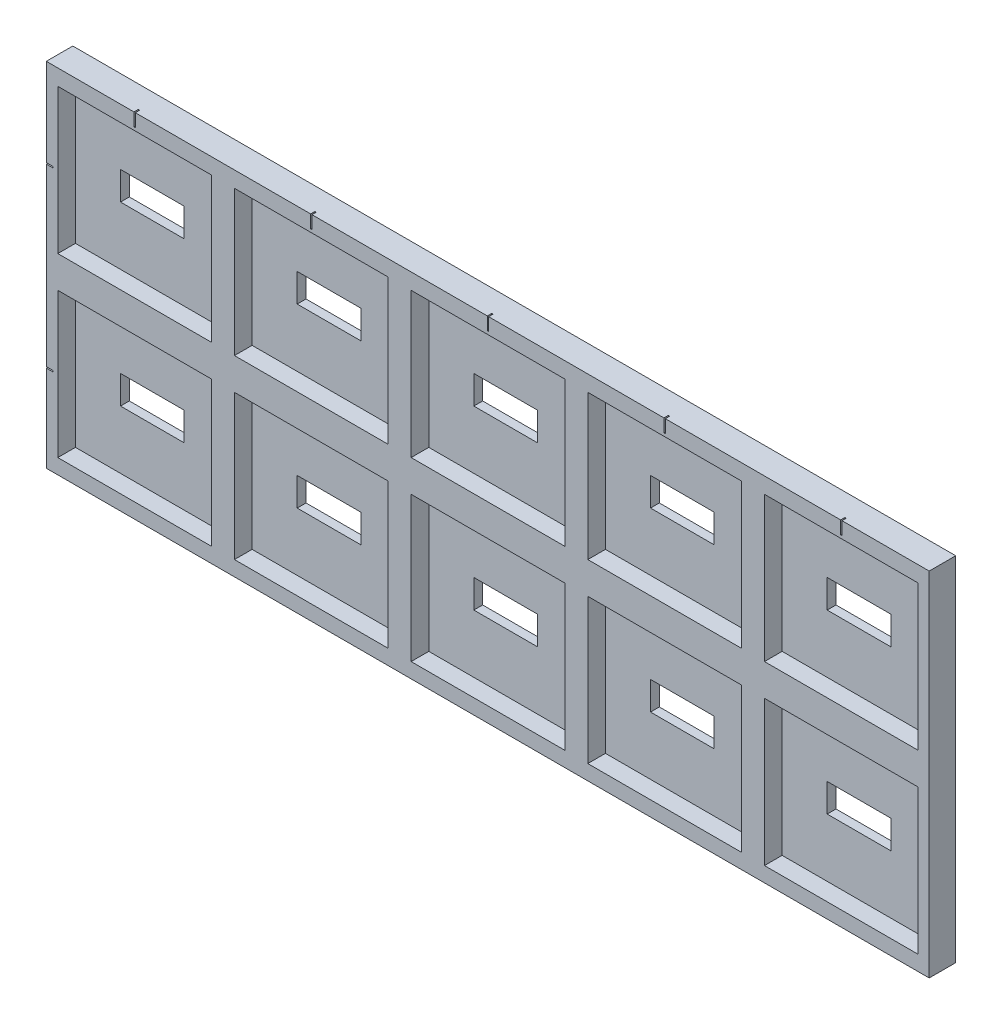
from build123d import *

# Parameters (mm, degrees)
TABLE_W                      = 99.948937608
TABLE_H                      = 39.897875217
BOSS_EXTRU_1_DEPTH           = 3
PINSPACE_W                   = 7.2
PINSPACE_H                   = 3.2
ENL_V_MAT_EXTRU_1_DEPTH      = 1
ENL_V_MAT_EXTRU_1_DEPTH_BACK = 4
ALCOVE_W                     = 17.4
ALCOVE_H                     = 16.4
ENL_V_MAT_EXTRU_2_DEPTH      = 2
ESQUISSE4_W                  = 0.15303985
ESQUISSE4_H                  = 1.630533914
ESQUISSE4_W_2                = 0.844812891
ESQUISSE4_H_2                = 0.146902924
ENL_V_MAT_EXTRU_3_DEPTH      = 0.5


with BuildPart() as part:
    # table → Boss.-Extru.1 (new body)
    with BuildSketch(Plane.XY):
        with Locations((39.974468804, -9.948937609)):
            Rectangle(TABLE_W, TABLE_H)
    extrude(amount=-BOSS_EXTRU_1_DEPTH)

    # pinspace → Enlèv. mat.-Extru.1 (cut, two sides)
    with BuildSketch(Plane.XY) as enl_v_mat_extru_1_sk:
        with Locations((20, 0)):
            Rectangle(PINSPACE_W, PINSPACE_H)
        Rectangle(PINSPACE_W, PINSPACE_H)
        with Locations((40, 0)):
            Rectangle(PINSPACE_W, PINSPACE_H)
        with Locations((60, 0)):
            Rectangle(PINSPACE_W, PINSPACE_H)
        with Locations((80, 0)):
            Rectangle(PINSPACE_W, PINSPACE_H)
        with Locations((20, -20)):
            Rectangle(PINSPACE_W, PINSPACE_H)
        with Locations((40, -20)):
            Rectangle(PINSPACE_W, PINSPACE_H)
        with Locations((60, -20)):
            Rectangle(PINSPACE_W, PINSPACE_H)
        with Locations((80, -20)):
            Rectangle(PINSPACE_W, PINSPACE_H)
        with Locations((0, -20)):
            Rectangle(PINSPACE_W, PINSPACE_H)
    extrude(amount=ENL_V_MAT_EXTRU_1_DEPTH, mode=Mode.SUBTRACT)
    extrude(enl_v_mat_extru_1_sk.sketch, amount=-ENL_V_MAT_EXTRU_1_DEPTH_BACK, mode=Mode.SUBTRACT)

    # alcove → Enlèv. mat.-Extru.2 (cut)
    with BuildSketch(Plane.XY):
        with Locations((20, 0)):
            Rectangle(ALCOVE_W, ALCOVE_H)
        Rectangle(ALCOVE_W, ALCOVE_H)
        with Locations((40, 0)):
            Rectangle(ALCOVE_W, ALCOVE_H)
        with Locations((60, 0)):
            Rectangle(ALCOVE_W, ALCOVE_H)
        with Locations((80, 0)):
            Rectangle(ALCOVE_W, ALCOVE_H)
        with Locations((20, -20)):
            Rectangle(ALCOVE_W, ALCOVE_H)
        with Locations((40, -20)):
            Rectangle(ALCOVE_W, ALCOVE_H)
        with Locations((60, -20)):
            Rectangle(ALCOVE_W, ALCOVE_H)
        with Locations((80, -20)):
            Rectangle(ALCOVE_W, ALCOVE_H)
        with Locations((0, -20)):
            Rectangle(ALCOVE_W, ALCOVE_H)
    extrude(amount=-ENL_V_MAT_EXTRU_2_DEPTH, mode=Mode.SUBTRACT)

    # Esquisse4 → Enlèv. mat.-Extru.3 (cut)
    with BuildSketch(Plane.XY):
        with Locations((0, 9.355457885)):
            Rectangle(ESQUISSE4_W, ESQUISSE4_H)
        with Locations((20, 9.355457885)):
            Rectangle(ESQUISSE4_W, ESQUISSE4_H)
        with Locations((40, 9.355457885)):
            Rectangle(ESQUISSE4_W, ESQUISSE4_H)
        with Locations((60, 9.355457885)):
            Rectangle(ESQUISSE4_W, ESQUISSE4_H)
        with Locations((80, 9.355457885)):
            Rectangle(ESQUISSE4_W, ESQUISSE4_H)
        with Locations((-9.685415881, 0)):
            Rectangle(ESQUISSE4_W_2, ESQUISSE4_H_2)
        with Locations((-9.685415881, -20)):
            Rectangle(ESQUISSE4_W_2, ESQUISSE4_H_2)
    extrude(amount=-ENL_V_MAT_EXTRU_3_DEPTH, mode=Mode.SUBTRACT)


solid = part.part
